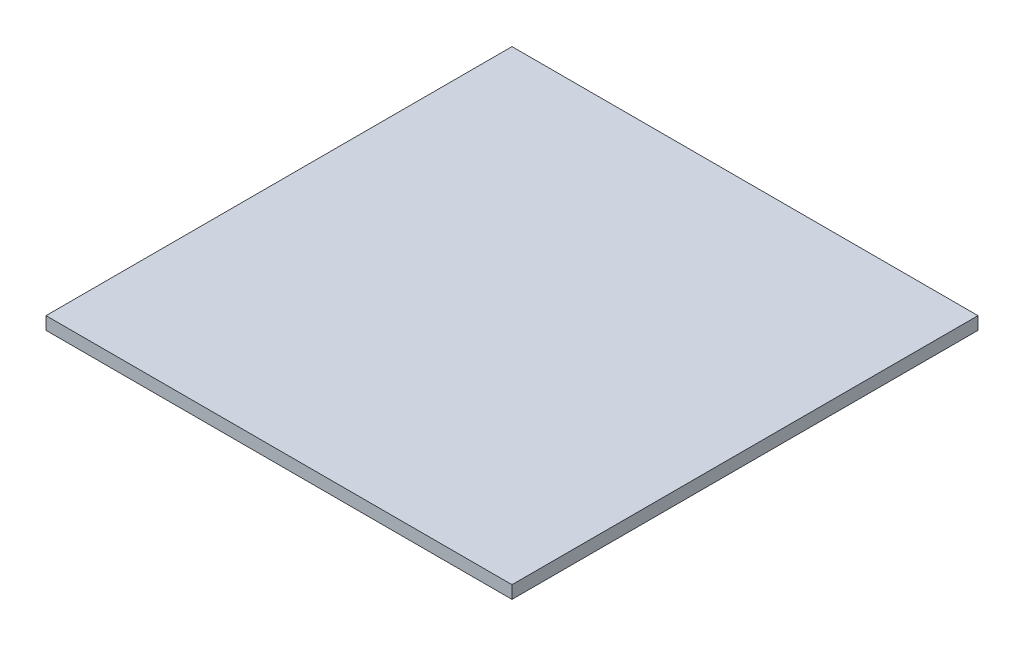
from build123d import *

# Parameters (mm, degrees)
SKETCH2_W           = 82.55
SKETCH2_H           = 82.55
BOSS_EXTRUDE1_DEPTH = 2.2606


with BuildPart() as part:
    # Sketch2 → Boss-Extrude1 (new body)
    with BuildSketch(Plane(origin=(0, 0, 0), x_dir=(1, 0, 0), z_dir=(0, 1, 0))):
        with Locations((-77.312048433, 23.858489416)):
            Rectangle(SKETCH2_W, SKETCH2_H)
    extrude(amount=BOSS_EXTRUDE1_DEPTH)


solid = part.part
